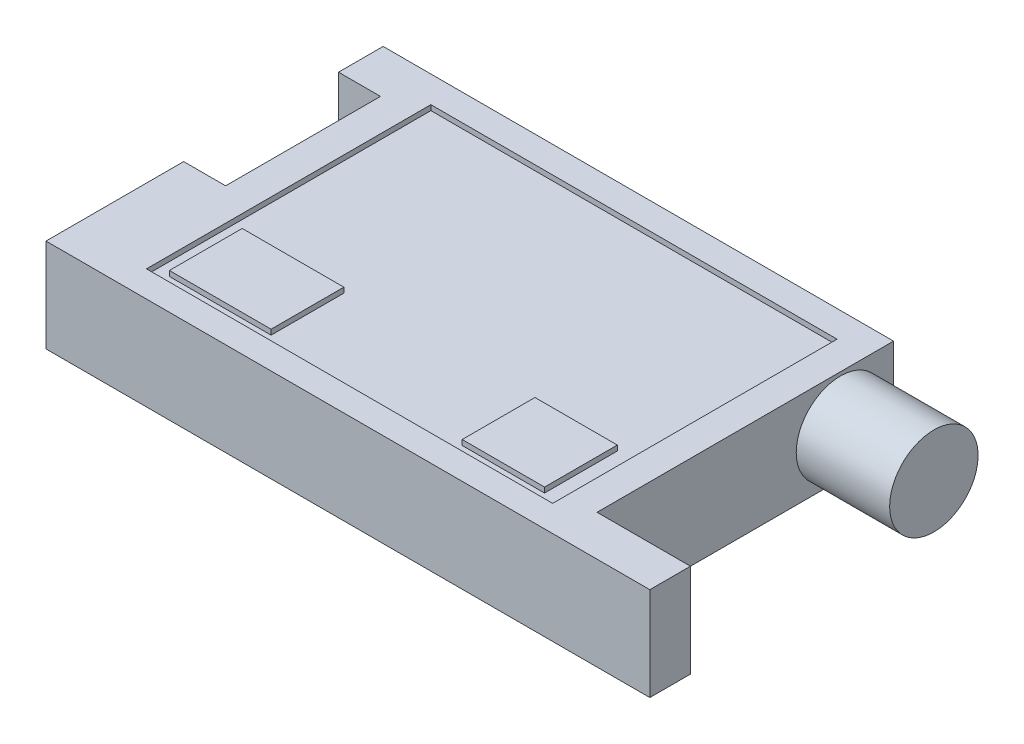
from build123d import *

# Parameters (mm, degrees)
BOSS_EXTRUDE1_DEPTH = 18
SKETCH2_R           = 8.516680521
BOSS_EXTRUDE2_DEPTH = 17.99267
SKETCH3_W           = 78.234373806
SKETCH3_H           = 54.777100321
CUT_EXTRUDE1_DEPTH  = 1
SKETCH4_W           = 15.862685655
SKETCH4_H           = 14.014084995
SKETCH4_W_2         = 19.585195724
BOSS_EXTRUDE3_DEPTH = 1
SKETCH5_W           = 4.110560002
SKETCH5_H           = 9.404487674
CUT_EXTRUDE2_DEPTH  = 9.590155657


with BuildPart() as part:
    # Sketch1 → Boss-Extrude1 (new body)
    with BuildSketch(Plane(origin=(0, 0, 0), x_dir=(1, 0, 0), z_dir=(0, 1, 0))):
        Polygon((-55.602513221, 28.358711105), (-55.602513221, 19.768555449), (-47.518849821, 19.768555449), (-47.518849821, -10.055277405), (-55.602513221, -10.055277405), (-55.602513221, -36.571359429), (60.697934404, -36.571359429), (60.697934404, -28.748459365), (42.705264255, -28.748459365), (42.705264255, 13.755964318), (42.705264255, 28.358711105), align=None)
    extrude(amount=BOSS_EXTRUDE1_DEPTH)

    # Sketch2 → Boss-Extrude2 (add)
    with BuildSketch(Plane(origin=(42.705264255, 0, 0), x_dir=(0, 0, -1), z_dir=(1, 0, 0))):
        with Locations(Location((18.133704787, 8.780998405, 0), (0, 0, 180))):  # turned: the seam where the file's is
            Circle(SKETCH2_R)
    extrude(amount=BOSS_EXTRUDE2_DEPTH)

    # Sketch3 → Cut-Extrude1 (cut)
    with BuildSketch(Plane(origin=(0, 18, 0), x_dir=(1, 0, 0), z_dir=(0, 1, 0))):
        with Locations((-2.172142095, -4.144542808)):
            Rectangle(SKETCH3_W, SKETCH3_H)
    extrude(amount=-CUT_EXTRUDE1_DEPTH, mode=Mode.SUBTRACT)

    # Sketch4 → Boss-Extrude3 (add)
    with BuildSketch(Plane(origin=(0, 17, 0), x_dir=(1, 0, 0), z_dir=(0, 1, 0))):
        with Locations((25.510271921, -22.585660372)):
            Rectangle(SKETCH4_W, SKETCH4_H)
        with Locations((-29.019306935, -22.585660372)):
            Rectangle(SKETCH4_W_2, SKETCH4_H)
    extrude(amount=BOSS_EXTRUDE3_DEPTH)

    # Sketch5 → Cut-Extrude2 (cut, through all)
    with BuildSketch(Plane.XY.offset(-19.768555449)):
        with Locations((-49.574129822, 8.723143931)):
            Rectangle(SKETCH5_W, SKETCH5_H)
    extrude(amount=-CUT_EXTRUDE2_DEPTH, mode=Mode.SUBTRACT)


solid = part.part
